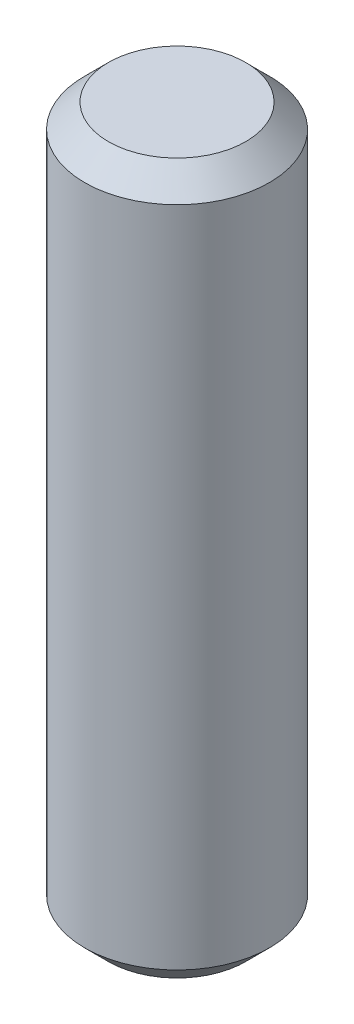
from build123d import *

# Parameters (mm, degrees)
SKETCH1_R           = 3.9
BOSS_EXTRUDE1_DEPTH = 15
CHAMFER1_SIZE       = 1


with BuildPart() as part:
    # Sketch1 → Boss-Extrude1 (new body, symmetric)
    with BuildSketch(Plane(origin=(0, 0, 0), x_dir=(1, 0, 0), z_dir=(0, 1, 0))):
        Circle(SKETCH1_R)
    extrude(amount=BOSS_EXTRUDE1_DEPTH, both=True)

    # Chamfer1
    chamfer1_edges = [part.edges().sort_by_distance(p)[0] for p in [
        (-3.9, -15, 0),
        (-3.9, 15, 0),
    ]]
    chamfer(chamfer1_edges, length=CHAMFER1_SIZE)


solid = part.part
